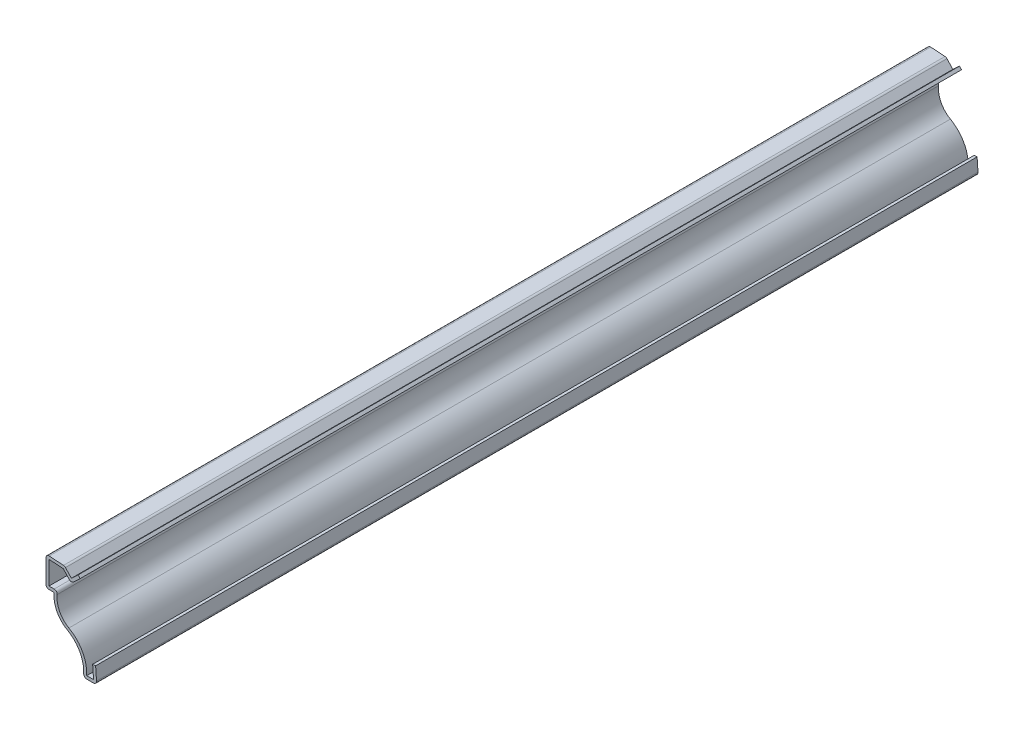
from build123d import *

# Parameters (mm, degrees)
EXTRUDE_THIN1_DEPTH = 261.9375
FILLET1_R           = 0.889


with BuildPart() as part:
    # Sketch1 → Extrude-Thin1 (new body)
    with BuildSketch(Plane.XY):
        with BuildLine():
            Line((-0.333026442, 4.7625), (0, 0))
            Line((0, 0), (-3.96875, 0))
            ThreePointArc((-3.96875, 0), (-4.818557487, 5.609954997), (-8.7077172, 9.741323362))
            ThreePointArc((-8.7077172, 9.741323362), (-11.842464504, 13.007739441), (-12.649448407, 17.4625))
            Line((-12.649448407, 17.4625), (-15.08125, 17.4625))
            Line((-15.08125, 17.4625), (-15.08125, 26.19375))
            Line((-15.08125, 26.19375), (-9.525, 25.805219151))
            Line((-9.525, 25.805219151), (-7.540625, 23.677237492))
            Line((-7.540625, 23.677237492), (-5.55625, 25.527697116))
            Line((-5.55625, 25.527697116), (-4.949953458, 24.877523675))
            Line((-4.949953458, 24.877523675), (-7.584501899, 22.420767509))
            Line((-7.584501899, 22.420767509), (-9.936346881, 24.94281248))
            Line((-9.936346881, 24.94281248), (-14.19225, 25.240414217))
            Line((-14.19225, 25.240414217), (-14.19225, 18.3515))
            Line((-14.19225, 18.3515), (-11.579833127, 18.3515))
            ThreePointArc((-11.579833127, 18.3515), (-11.263384071, 13.868774929), (-8.271283672, 10.515821118))
            ThreePointArc((-8.271283672, 10.515821118), (-4.255672213, 6.4560014), (-2.984543996, 0.889))
            Line((-2.984543996, 0.889), (-0.953335783, 0.889))
            Line((-0.953335783, 0.889), (-1.219860883, 4.700486495))
            Line((-1.219860883, 4.700486495), (-0.333026442, 4.7625))
        make_face()
    extrude(amount=-EXTRUDE_THIN1_DEPTH)

    # Fillet1
    fillet1_edges = [part.edges().sort_by_distance(p)[0] for p in [
        (-7.584501899, 22.420767509, -130.96875),
        (-11.579833127, 18.3515, -130.96875),
        (0, 0, -130.96875),
        (-3.96875, 0, -130.96875),
        (-15.08125, 17.4625, -130.96875),
        (-15.08125, 26.19375, -130.96875),
        (-9.525, 25.805219151, -130.96875),
    ]]
    fillet(fillet1_edges, radius=FILLET1_R)


solid = part.part
